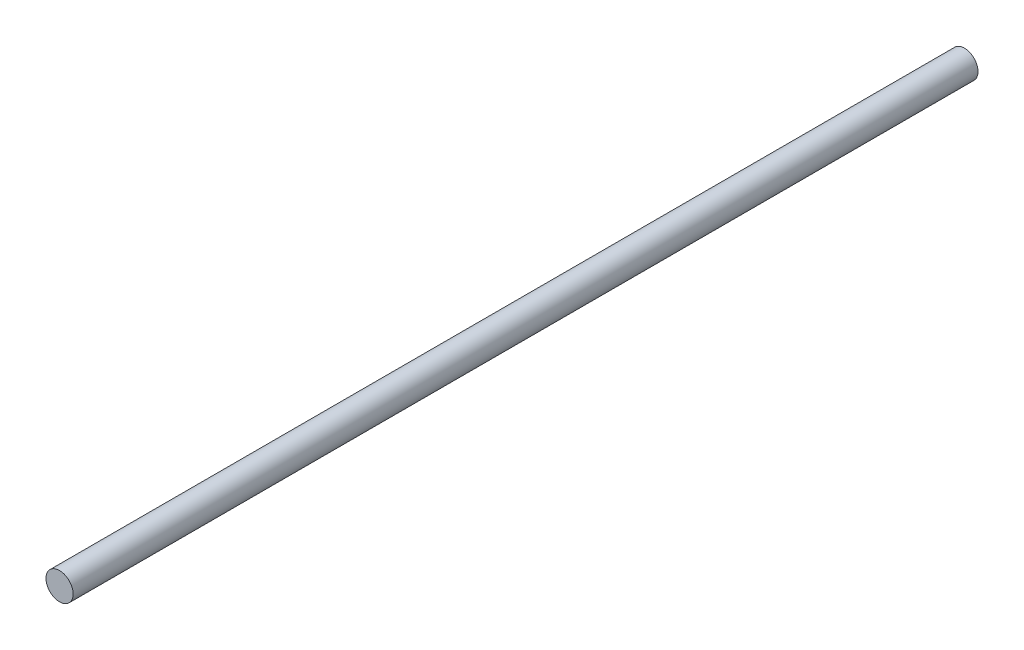
from build123d import *

# Parameters (mm, degrees)
SKETCH1_R  = 3
MAIN_DEPTH = 200


with BuildPart() as part:
    # Sketch1 → Main (new body)
    with BuildSketch(Plane.XY):
        Circle(SKETCH1_R)
    extrude(amount=MAIN_DEPTH)


solid = part.part
